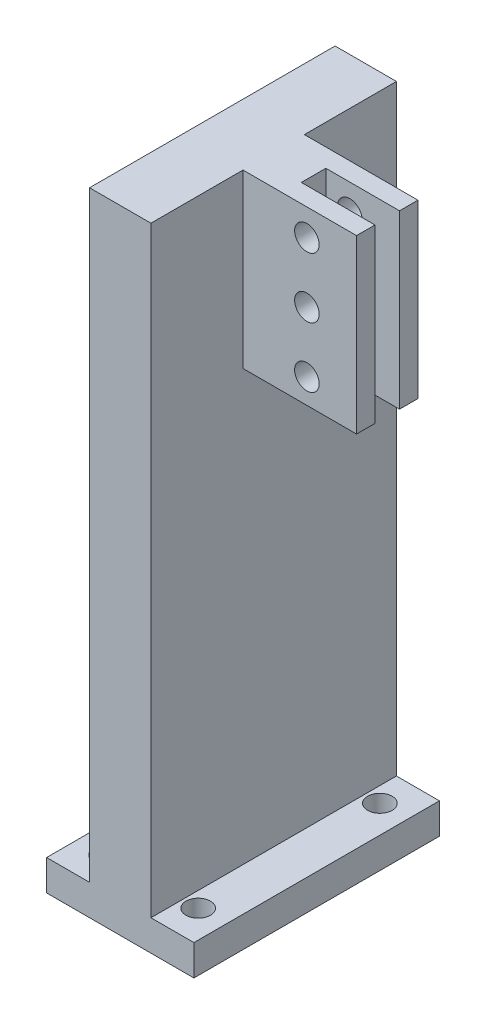
from build123d import *

# Parameters (mm, degrees)
SKETCH_1_W          = 24
SKETCH_1_H          = 40
SKETCH_1_R          = 2
EXTRUDE_1_DEPTH     = 5
EXTRUDE_5_DEPTH     = 98
SKETCH_10_W         = 10
SKETCH_10_H         = 28
EXTRUDE_6_DEPTH     = 18.5
SKETCH_12_R         = 2
CUT_EXTRUDE_4_DEPTH = 24.5
SKETCH_13_W         = 12
SKETCH_13_H         = 28
CUT_EXTRUDE_5_DEPTH = 2


with BuildPart() as part:
    # 草图1 → 凸台-拉伸1 (new body)
    with BuildSketch(Plane(origin=(0, 0, 0), x_dir=(1, 0, 0), z_dir=(0, 1, 0))):
        Rectangle(SKETCH_1_W, SKETCH_1_H)
        with Locations((7.5, -14.8)):
            Circle(SKETCH_1_R, mode=Mode.SUBTRACT)
        with Locations((-7.5, -14.8)):
            Circle(SKETCH_1_R, mode=Mode.SUBTRACT)
        with Locations((-7.5, 14.8)):
            Circle(SKETCH_1_R, mode=Mode.SUBTRACT)
        with Locations((7.5, 14.8)):
            Circle(SKETCH_1_R, mode=Mode.SUBTRACT)
    extrude(amount=EXTRUDE_1_DEPTH)

    # 草图8 → 凸台-拉伸5 (add)
    with BuildSketch(Plane(origin=(0, 5, 0), x_dir=(1, 0, 0), z_dir=(0, 1, 0))):
        Polygon((-5, 0), (-5, -20), (5, -20), (5, 20), (-5, 20), align=None)
    extrude(amount=EXTRUDE_5_DEPTH)

    # 草图10 → 凸台-拉伸6 (add)
    with BuildSketch(Plane(origin=(5, 0, 0), x_dir=(0, 0, -1), z_dir=(1, 0, 0))):
        with Locations((0, 89)):
            Rectangle(SKETCH_10_W, SKETCH_10_H)
    extrude(amount=EXTRUDE_6_DEPTH)

    # 草图12 → 切除-拉伸4 (cut)
    with BuildSketch(Plane(origin=(0, 0, -5), x_dir=(-1, 0, 0), z_dir=(0, 0, -1))):
        with Locations((-15.41, 98.67)):
            Circle(SKETCH_12_R)
        with Locations((-15.41, 88.85)):
            Circle(SKETCH_12_R)
        with Locations((-15.41, 79.03)):
            Circle(SKETCH_12_R)
    extrude(amount=-CUT_EXTRUDE_4_DEPTH, mode=Mode.SUBTRACT)

    # 草图13 → 切除-拉伸5 (cut, symmetric)
    with BuildSketch(Plane.XY):
        with Locations((17.5, 89)):
            Rectangle(SKETCH_13_W, SKETCH_13_H)
    extrude(amount=CUT_EXTRUDE_5_DEPTH, both=True, mode=Mode.SUBTRACT)


solid = part.part
